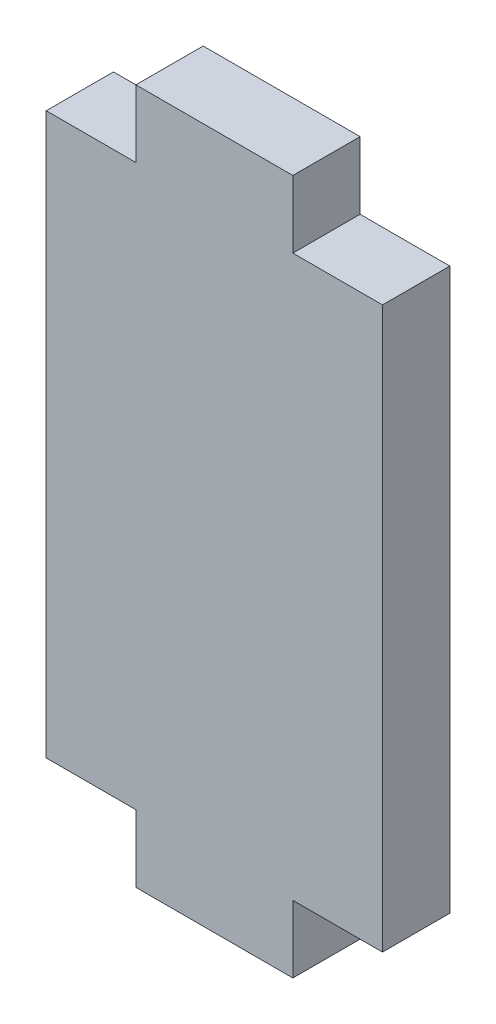
from build123d import *

# Parameters (mm, degrees)
BOSS_EXTRUDE1_DEPTH = 1.5


with BuildPart() as part:
    # Sketch1 → Boss-Extrude1 (new body, symmetric)
    with BuildSketch(Plane.XY):
        Polygon((3.5, 12.5), (7.5, 12.5), (7.5, -12.5), (3.5, -12.5), (3.5, -15.5), (-3.5, -15.5), (-3.5, -12.5), (-7.5, -12.5), (-7.5, 12.5), (-3.5, 12.5), (-3.5, 15.5), (3.5, 15.5), align=None)
    extrude(amount=BOSS_EXTRUDE1_DEPTH, both=True)


solid = part.part
